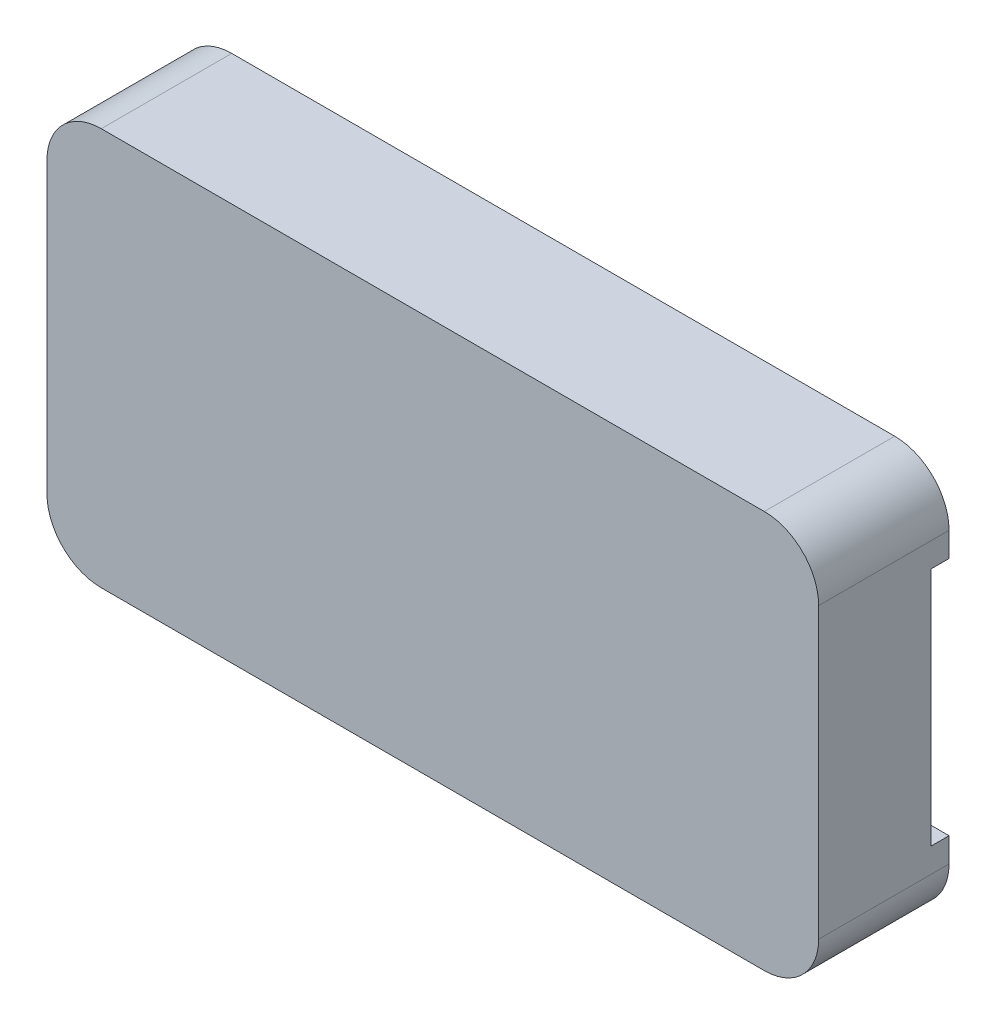
from build123d import *

# Parameters (mm, degrees)
SKETCH2_W           = 42.6
SKETCH2_H           = 21.95
BOSS_EXTRUDE1_DEPTH = 7.2
FILLET1_R           = 3
SKETCH3_W           = 4.07
SKETCH3_H           = 13.25
CUT_EXTRUDE1_DEPTH  = 5.2
BOSS_EXTRUDE2_DEPTH = 5.2
BOSS_EXTRUDE3_DEPTH = 4.2


with BuildPart() as part:
    # Sketch2 → Boss-Extrude1 (new body)
    with BuildSketch(Plane.XY):
        Rectangle(SKETCH2_W, SKETCH2_H)
    extrude(amount=BOSS_EXTRUDE1_DEPTH)

    # Fillet1
    fillet1_edges = [part.edges().sort_by_distance(p)[0] for p in [
        (-21.3, 10.975, 3.6),
        (21.3, 10.975, 3.6),
        (21.3, -10.975, 3.6),
        (-21.3, -10.975, 3.6),
    ]]
    fillet(fillet1_edges, radius=FILLET1_R)

    # Sketch3 → Cut-Extrude1 (cut)
    with BuildSketch(Plane(origin=(0, 0, 0), x_dir=(-1, 0, 0), z_dir=(0, 0, -1))):
        with Locations((-19.265, 0)):
            Rectangle(SKETCH3_W, SKETCH3_H)
    extrude(amount=-CUT_EXTRUDE1_DEPTH, mode=Mode.SUBTRACT)

    # Sketch4 → Boss-Extrude2 (add)
    with BuildSketch(Plane(origin=(0, 0, 5.2), x_dir=(-1, 0, 0), z_dir=(0, 0, -1))):
        Polygon((-20.15, 4.925), (-20.15, -4.925), (-18.4, -4.925), (-18.4, -3.815), (-19.11, -3.815), (-19.11, -0.555), (-18.4, -0.555), (-18.4, 0.555), (-19.11, 0.555), (-19.11, 3.815), (-18.4, 3.815), (-18.4, 4.925), align=None)
    extrude(amount=BOSS_EXTRUDE2_DEPTH)

    # Sketch5 → Boss-Extrude3 (add)
    with BuildSketch(Plane(origin=(0, 0, 5.2), x_dir=(-1, 0, 0), z_dir=(0, 0, -1))):
        Polygon((-21.3, 6.625), (-21.3, -6.625), (-19.9, -6.625), (-19.9, -4.925), (-20.15, -4.925), (-20.15, 4.925), (-19.9, 4.925), (-19.9, 6.625), align=None)
    extrude(amount=BOSS_EXTRUDE3_DEPTH)


solid = part.part
